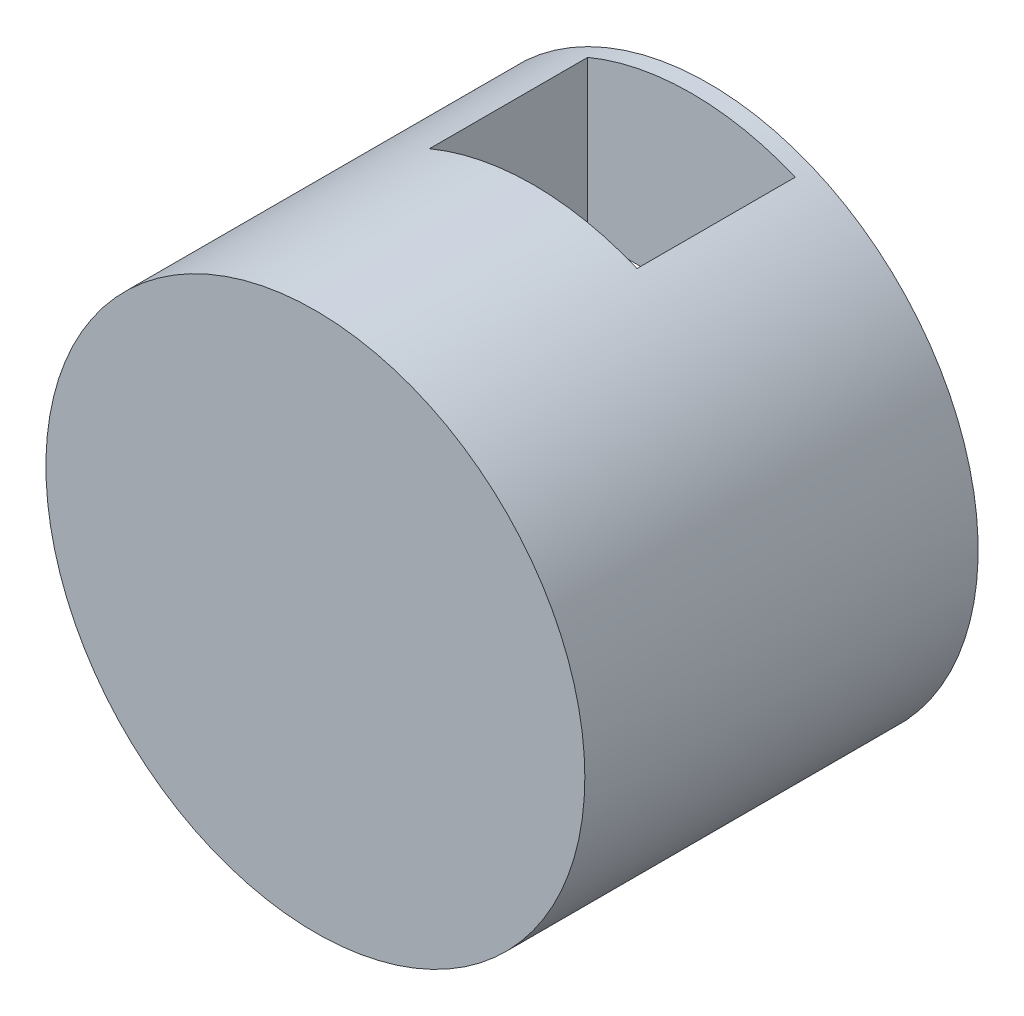
from build123d import *

# Parameters (mm, degrees)
SKETCH1_R           = 23.5
BOSS_EXTRUDE1_DEPTH = 32.8
SKETCH5_W           = 18.1
SKETCH5_H           = 47
CUT_EXTRUDE1_DEPTH  = 13.8
SKETCH6_R           = 23.5
BOSS_EXTRUDE2_DEPTH = 1.5
CUT_EXTRUDE5_DEPTH  = 1.5


with BuildPart() as part:
    # Sketch1 → Boss-Extrude1 (new body)
    with BuildSketch(Plane.XY):
        Circle(SKETCH1_R)
    extrude(amount=BOSS_EXTRUDE1_DEPTH)

    # Sketch5 → Cut-Extrude1 (cut)
    with BuildSketch(Plane(origin=(0, 0, 0), x_dir=(-1, 0, 0), z_dir=(0, 0, -1))):
        Rectangle(SKETCH5_W, SKETCH5_H)
    extrude(amount=-CUT_EXTRUDE1_DEPTH, mode=Mode.SUBTRACT)

    # Sketch6 → Boss-Extrude2 (add)
    with BuildSketch(Plane.XY):
        Circle(SKETCH6_R)
    extrude(amount=-BOSS_EXTRUDE2_DEPTH)

    # Sketch8 → Cut-Extrude5 (cut)
    with BuildSketch(Plane(origin=(0, 0, -1.5), x_dir=(-1, 0, 0), z_dir=(0, 0, -1))):
        with BuildLine():
            Line((-9.05, 8.2), (9.05, 8.2))
            Line((9.05, 8.2), (9.05, -21.687496398))
            ThreePointArc((9.05, -21.687496398), (0, -23.5), (-9.05, -21.687496398))
            Line((-9.05, -21.687496398), (-9.05, 8.2))
        make_face()
    extrude(amount=-CUT_EXTRUDE5_DEPTH, mode=Mode.SUBTRACT)


solid = part.part
